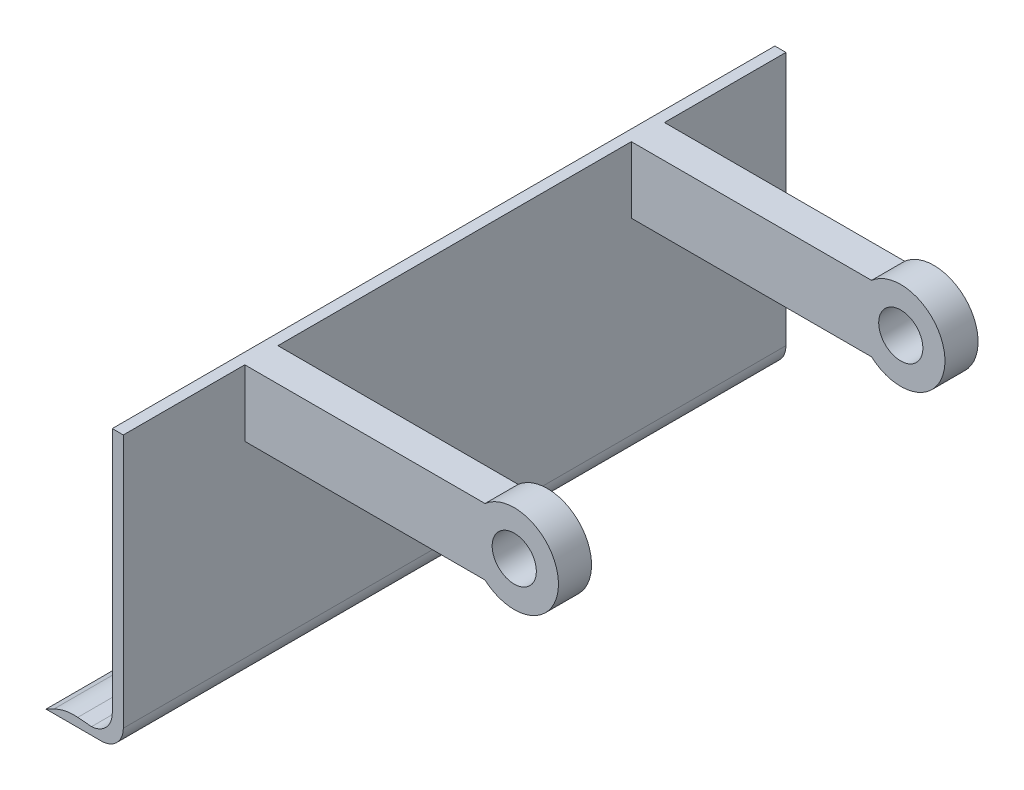
from build123d import *

# Parameters (mm, degrees)
BOSS_EXTRU_1_DEPTH      = 300
ESQUISSE3_W             = 15
ESQUISSE3_H             = 30
BOSS_EXTRU_2_DEPTH      = 115
ESQUISSE4_R             = 20
BOSS_EXTRU_3_DEPTH      = 15
ESQUISSE6_R             = 20
BOSS_EXTRU_4_DEPTH      = 15
ESQUISSE5_R             = 10
ENL_V_MAT_EXTRU_1_DEPTH = 246


with BuildPart() as part:
    # Esquisse1 → Boss.-Extru.1 (new body)
    with BuildSketch(Plane.XY):
        with BuildLine():
            Line((-5, 125), (-5, 35))
            Line((-5, 35), (-5, 13.417991274))
            ThreePointArc((-5, 13.417991274), (-7.715430946, 6.567075008), (-14.387010739, 3.436796748))
            Line((-14.387010739, 3.436796748), (-20.619947118, 3.962528759))
            ThreePointArc((-20.619947118, 3.962528759), (-26.167850826, 3.655908021), (-31.417293187, 1.834752694))
            Line((-31.417293187, 1.834752694), (-35, 0))
            Line((-35, 0), (-10, 0))
            ThreePointArc((-10, 0), (-2.928932188, 2.928932188), (0, 10))
            Line((0, 10), (0, 30))
            Line((0, 30), (0, 125))
            Line((0, 125), (-5, 125))
        make_face()
    extrude(amount=BOSS_EXTRU_1_DEPTH)

    # Esquisse3 → Boss.-Extru.2 (add)
    with BuildSketch(Plane(origin=(0, 0, 0), x_dir=(0, 0, -1), z_dir=(1, 0, 0))):
        with Locations((-237.5, 110)):
            Rectangle(ESQUISSE3_W, ESQUISSE3_H)
        with Locations((-62.5, 110)):
            Rectangle(ESQUISSE3_W, ESQUISSE3_H)
    extrude(amount=BOSS_EXTRU_2_DEPTH)

    # Esquisse4 → Boss.-Extru.3 (add)
    with BuildSketch(Plane.XY.offset(245)):
        with Locations((122, 110)):
            Circle(ESQUISSE4_R)
    extrude(amount=-BOSS_EXTRU_3_DEPTH)

    # Esquisse6 → Boss.-Extru.4 (add)
    with BuildSketch(Plane.XY.offset(70)):
        with Locations((122, 110)):
            Circle(ESQUISSE6_R)
    extrude(amount=-BOSS_EXTRU_4_DEPTH)

    # Esquisse5 → Enlèv. mat.-Extru.1 (cut, through all)
    with BuildSketch(Plane.XY.offset(245)):
        with Locations((122, 110)):
            Circle(ESQUISSE5_R)
    extrude(amount=-ENL_V_MAT_EXTRU_1_DEPTH, mode=Mode.SUBTRACT)


solid = part.part
